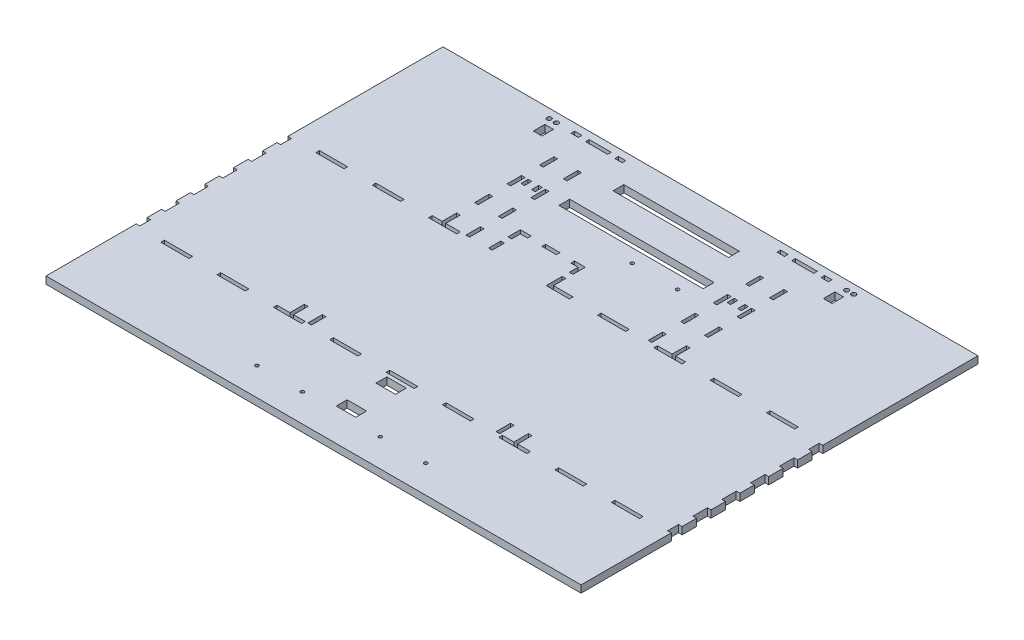
from build123d import *

# Parameters (mm, degrees)
SKETCH1_W                   = 470.789
SKETCH1_H                   = 139.7
BOSS_EXTRUDE1_DEPTH         = 6.35
SKETCH2_W                   = 470.789
SKETCH2_H                   = 139.7
SKETCH2_W_2                 = 464.439
SKETCH2_H_2                 = 133.35
BOSS_EXTRUDE2_DEPTH         = 298.45
SKETCH3_W                   = 5.588
SKETCH3_H                   = 16.933333333
SKETCH3_H_2                 = 16.933333334
DOOR_SLOT_DEPTH             = 12.7
SKETCH4_W                   = 6.35
SKETCH4_H                   = 15.875
DOOR_GUIDE_HOLES_DEPTH      = 3.175
LEVERHOLE_CUT_REACH         = 141.7
LEVER_HOLES_R               = 1.5
LEVER_HOLES_W               = 25.4
LEVER_HOLES_H               = 7.62
LEVER_HOLES_W_2             = 4
LEVER_HOLES_H_2             = 6.35
LEVER_HOLES_2_R             = 1.5
LBRACKET_THRU_HOLES_DEPTH   = 140.7
SKETCH8_R                   = 3.175
TETHER_HOLE_DEPTH           = 471.789
DOOR_GUIDE_ROOF_SLOTS_REACH = 141.7
SKETCH16_W                  = 9.525
SKETCH16_H                  = 9.271
SKETCH17_W                  = 470.789
SKETCH17_H                  = 298.45
CUT_EXTRUDE10_DEPTH         = 140.7
BOTTOM_W                    = 24.778368421
BOTTOM_H                    = 3.175
BOTTOM_W_2                  = 24.778368422
BOTTOM_W_3                  = 3.175
BOTTOM_H_2                  = 9.525
BOTTOM_H_3                  = 12.7
CUT_EXTRUDE11_DEPTH         = 7.35
SKETCH18_W                  = 470.789
SKETCH18_H                  = 76.2
SKETCH18_W_2                = 6.477
SKETCH18_H_2                = 3.175
SKETCH18_W_3                = 19.431
SKETCH18_W_4                = 3.175
SKETCH18_H_3                = 12.7
SKETCH18_W_5                = 12.7
BOSS_EXTRUDE3_DEPTH         = 6.35
SKETCH19_R                  = 1.499997
SKETCH19_R_2                = 2
SKETCH19_W                  = 3.175
SKETCH19_H                  = 6.35
CUT_EXTRUDE12_DEPTH         = 7.35
SKETCH20_W                  = 3.175
SKETCH20_H                  = 12.7
CUT_EXTRUDE13_DEPTH         = 7.35
SKETCH21_W                  = 17.145
SKETCH21_H                  = 9.525
SKETCH21_W_2                = 7.62
SKETCH21_H_2                = 10.16
SKETCH21_W_3                = 101.6
SKETCH21_W_4                = 127
WIRE_HOLES_DEPTH            = 7.35


with BuildPart() as part:
    # Sketch1 → Boss-Extrude1 (new body)
    with BuildSketch(Plane(origin=(0, 0, 0), x_dir=(1, 0, 0), z_dir=(0, 1, 0))):
        Rectangle(SKETCH1_W, SKETCH1_H)
    extrude(amount=BOSS_EXTRUDE1_DEPTH)

    # Sketch2 → Boss-Extrude2 (add)
    with BuildSketch(Plane(origin=(0, 6.35, 0), x_dir=(1, 0, 0), z_dir=(0, 1, 0))):
        Rectangle(SKETCH2_W, SKETCH2_H)
        Rectangle(SKETCH2_W_2, SKETCH2_H_2, mode=Mode.SUBTRACT)
    extrude(amount=BOSS_EXTRUDE2_DEPTH)

    # Sketch3 → Door Slot (cut)
    with BuildSketch(Plane.XY.offset(69.85)):
        with BuildLine():
            Line((70.1675, 292.354), (70.1675, 6.35))
            Line((70.1675, 6.35), (76.7715, 6.35))
            Line((76.7715, 6.35), (76.7715, 283.240675824))
            ThreePointArc((76.7715, 283.240675824), (77.515448776, 285.036727048), (79.3115, 285.780675824))
            Line((79.3115, 285.780675824), (89.7255, 285.780675824))
            Line((89.7255, 285.780675824), (89.7255, 292.354))
            Line((89.7255, 292.354), (70.1675, 292.354))
        make_face()
        with Locations((60.2615, 80.433333334)):
            Rectangle(SKETCH3_W, SKETCH3_H)
        with Locations((60.2615, 50.8)):
            Rectangle(SKETCH3_W, SKETCH3_H_2)
        with Locations((60.2615, 21.166666667)):
            Rectangle(SKETCH3_W, SKETCH3_H)
        with BuildLine():
            Line((-76.7715, 283.240675824), (-76.7715, 6.35))
            Line((-76.7715, 6.35), (-70.1675, 6.35))
            Line((-70.1675, 6.35), (-70.1675, 292.354))
            Line((-70.1675, 292.354), (-89.7255, 292.354))
            Line((-89.7255, 292.354), (-89.7255, 285.780675824))
            Line((-89.7255, 285.780675824), (-79.3115, 285.780675824))
            ThreePointArc((-79.3115, 285.780675824), (-77.515448776, 285.036727048), (-76.7715, 283.240675824))
        make_face()
        with Locations((-60.2615, 80.433333334)):
            Rectangle(SKETCH3_W, SKETCH3_H)
        with Locations((-60.2615, 50.8)):
            Rectangle(SKETCH3_W, SKETCH3_H_2)
        with Locations((-60.2615, 21.166666667)):
            Rectangle(SKETCH3_W, SKETCH3_H)
    extrude(amount=-DOOR_SLOT_DEPTH, mode=Mode.SUBTRACT)

    # Sketch4 → Door Guide Holes (cut)
    with BuildSketch(Plane.XY.offset(-66.675)):
        with Locations((66.9925, 255.5875)):
            Rectangle(SKETCH4_W, SKETCH4_H)
        with Locations((66.9925, 227.0125)):
            Rectangle(SKETCH4_W, SKETCH4_H)
        with Locations((66.9925, 198.4375)):
            Rectangle(SKETCH4_W, SKETCH4_H)
        with Locations((66.9925, 169.8625)):
            Rectangle(SKETCH4_W, SKETCH4_H)
        with Locations((66.9925, 141.2875)):
            Rectangle(SKETCH4_W, SKETCH4_H)
        with Locations((66.9925, 112.7125)):
            Rectangle(SKETCH4_W, SKETCH4_H)
        with Locations((66.9925, 84.1375)):
            Rectangle(SKETCH4_W, SKETCH4_H)
        with Locations((66.9925, 55.5625)):
            Rectangle(SKETCH4_W, SKETCH4_H)
        with Locations((66.9925, 26.9875)):
            Rectangle(SKETCH4_W, SKETCH4_H)
        with Locations((-92.9005, 284.1625)):
            Rectangle(SKETCH4_W, SKETCH4_H)
        with Locations((-92.9005, 255.5875)):
            Rectangle(SKETCH4_W, SKETCH4_H)
        with Locations((-92.9005, 227.0125)):
            Rectangle(SKETCH4_W, SKETCH4_H)
        with Locations((-92.9005, 198.4375)):
            Rectangle(SKETCH4_W, SKETCH4_H)
        with Locations((-92.9005, 169.8625)):
            Rectangle(SKETCH4_W, SKETCH4_H)
        with Locations((-92.9005, 141.2875)):
            Rectangle(SKETCH4_W, SKETCH4_H)
        with Locations((-92.9005, 112.7125)):
            Rectangle(SKETCH4_W, SKETCH4_H)
        with Locations((-92.9005, 84.1375)):
            Rectangle(SKETCH4_W, SKETCH4_H)
        with Locations((-92.9005, 55.5625)):
            Rectangle(SKETCH4_W, SKETCH4_H)
        with Locations((-92.9005, 26.9875)):
            Rectangle(SKETCH4_W, SKETCH4_H)
        with Locations((92.9005, 284.1625)):
            Rectangle(SKETCH4_W, SKETCH4_H)
        with Locations((92.9005, 255.5875)):
            Rectangle(SKETCH4_W, SKETCH4_H)
        with Locations((92.9005, 227.0125)):
            Rectangle(SKETCH4_W, SKETCH4_H)
        with Locations((92.9005, 198.4375)):
            Rectangle(SKETCH4_W, SKETCH4_H)
        with Locations((92.9005, 169.8625)):
            Rectangle(SKETCH4_W, SKETCH4_H)
        with Locations((92.9005, 141.2875)):
            Rectangle(SKETCH4_W, SKETCH4_H)
        with Locations((92.9005, 112.7125)):
            Rectangle(SKETCH4_W, SKETCH4_H)
        with Locations((92.9005, 84.1375)):
            Rectangle(SKETCH4_W, SKETCH4_H)
        with Locations((92.9005, 55.5625)):
            Rectangle(SKETCH4_W, SKETCH4_H)
        with Locations((92.9005, 26.9875)):
            Rectangle(SKETCH4_W, SKETCH4_H)
        with Locations((-66.9925, 284.1625)):
            Rectangle(SKETCH4_W, SKETCH4_H)
        with Locations((-66.9925, 255.5875)):
            Rectangle(SKETCH4_W, SKETCH4_H)
        with Locations((-66.9925, 227.0125)):
            Rectangle(SKETCH4_W, SKETCH4_H)
        with Locations((-66.9925, 198.4375)):
            Rectangle(SKETCH4_W, SKETCH4_H)
        with Locations((-66.9925, 169.8625)):
            Rectangle(SKETCH4_W, SKETCH4_H)
        with Locations((-66.9925, 141.2875)):
            Rectangle(SKETCH4_W, SKETCH4_H)
        with Locations((-66.9925, 112.7125)):
            Rectangle(SKETCH4_W, SKETCH4_H)
        with Locations((-66.9925, 84.1375)):
            Rectangle(SKETCH4_W, SKETCH4_H)
        with Locations((-66.9925, 55.5625)):
            Rectangle(SKETCH4_W, SKETCH4_H)
        with Locations((-66.9925, 26.9875)):
            Rectangle(SKETCH4_W, SKETCH4_H)
        with Locations((66.9925, 284.1625)):
            Rectangle(SKETCH4_W, SKETCH4_H)
    extrude(amount=-DOOR_GUIDE_HOLES_DEPTH, mode=Mode.SUBTRACT)

    # Lever Holes → LeverHole Cut (cut, up to next)
    with BuildSketch(Plane.XY.offset(-69.85), mode=Mode.PRIVATE) as leverhole_cut_sk1:
        with Locations((216.3445, 160.275)):
            Circle(LEVER_HOLES_R)
    leverhole_cut_tool1 = extrude(leverhole_cut_sk1.sketch, amount=LEVERHOLE_CUT_REACH, mode=Mode.PRIVATE) & part.part
    add(leverhole_cut_tool1.solids().sort_by_distance((216.3445, 160.275, -69.85))[0], mode=Mode.SUBTRACT)
    # Lever Holes → LeverHole Cut (cut, up to next)
    with BuildSketch(Plane.XY.offset(-69.85), mode=Mode.PRIVATE) as leverhole_cut_sk2:
        with Locations((216.3445, 144.525)):
            Circle(LEVER_HOLES_R)
    leverhole_cut_tool2 = extrude(leverhole_cut_sk2.sketch, amount=LEVERHOLE_CUT_REACH, mode=Mode.PRIVATE) & part.part
    add(leverhole_cut_tool2.solids().sort_by_distance((216.3445, 144.525, -69.85))[0], mode=Mode.SUBTRACT)
    # Lever Holes → LeverHole Cut (cut, up to next)
    with BuildSketch(Plane.XY.offset(-69.85), mode=Mode.PRIVATE) as leverhole_cut_sk3:
        with Locations((-216.3445, 160.275)):
            Circle(LEVER_HOLES_R)
    leverhole_cut_tool3 = extrude(leverhole_cut_sk3.sketch, amount=LEVERHOLE_CUT_REACH, mode=Mode.PRIVATE) & part.part
    add(leverhole_cut_tool3.solids().sort_by_distance((-216.3445, 160.275, -69.85))[0], mode=Mode.SUBTRACT)
    # Lever Holes → LeverHole Cut (cut, up to next)
    with BuildSketch(Plane.XY.offset(-69.85), mode=Mode.PRIVATE) as leverhole_cut_sk4:
        with Locations((-216.3445, 144.525)):
            Circle(LEVER_HOLES_R)
    leverhole_cut_tool4 = extrude(leverhole_cut_sk4.sketch, amount=LEVERHOLE_CUT_REACH, mode=Mode.PRIVATE) & part.part
    add(leverhole_cut_tool4.solids().sort_by_distance((-216.3445, 144.525, -69.85))[0], mode=Mode.SUBTRACT)
    # Lever Holes → LeverHole Cut (cut, up to next)
    with BuildSketch(Plane.XY.offset(-69.85), mode=Mode.PRIVATE) as leverhole_cut_sk5:
        with Locations((-40.5675, 33.8749894)):
            Rectangle(LEVER_HOLES_W, LEVER_HOLES_H)
    leverhole_cut_tool5 = extrude(leverhole_cut_sk5.sketch, amount=LEVERHOLE_CUT_REACH, mode=Mode.PRIVATE) & part.part
    add(leverhole_cut_tool5.solids().sort_by_distance((-40.5675, 33.874989, -69.85))[0], mode=Mode.SUBTRACT)
    # Lever Holes → LeverHole Cut (cut, up to next)
    with BuildSketch(Plane.XY.offset(-69.85), mode=Mode.PRIVATE) as leverhole_cut_sk6:
        with Locations((-51.8175, 13.175)):
            Rectangle(LEVER_HOLES_W_2, LEVER_HOLES_H_2)
    leverhole_cut_tool6 = extrude(leverhole_cut_sk6.sketch, amount=LEVERHOLE_CUT_REACH, mode=Mode.PRIVATE) & part.part
    add(leverhole_cut_tool6.solids().sort_by_distance((-51.8175, 13.175, -69.85))[0], mode=Mode.SUBTRACT)
    # Lever Holes → LeverHole Cut (cut, up to next)
    with BuildSketch(Plane.XY.offset(-69.85), mode=Mode.PRIVATE) as leverhole_cut_sk7:
        with Locations((-5.8175068, 13.175)):
            Rectangle(LEVER_HOLES_W_2, LEVER_HOLES_H_2)
    leverhole_cut_tool7 = extrude(leverhole_cut_sk7.sketch, amount=LEVERHOLE_CUT_REACH, mode=Mode.PRIVATE) & part.part
    add(leverhole_cut_tool7.solids().sort_by_distance((-5.817507, 13.175, -69.85))[0], mode=Mode.SUBTRACT)
    # Lever Holes → LeverHole Cut (cut, up to next)
    with BuildSketch(Plane.XY.offset(-69.85), mode=Mode.PRIVATE) as leverhole_cut_sk8:
        with Locations((5.8175068, 13.175)):
            Rectangle(LEVER_HOLES_W_2, LEVER_HOLES_H_2)
    leverhole_cut_tool8 = extrude(leverhole_cut_sk8.sketch, amount=LEVERHOLE_CUT_REACH, mode=Mode.PRIVATE) & part.part
    add(leverhole_cut_tool8.solids().sort_by_distance((5.817507, 13.175, -69.85))[0], mode=Mode.SUBTRACT)
    # Lever Holes → LeverHole Cut (cut, up to next)
    with BuildSketch(Plane.XY.offset(-69.85), mode=Mode.PRIVATE) as leverhole_cut_sk9:
        with Locations((40.5675, 33.8749894)):
            Rectangle(LEVER_HOLES_W, LEVER_HOLES_H)
    leverhole_cut_tool9 = extrude(leverhole_cut_sk9.sketch, amount=LEVERHOLE_CUT_REACH, mode=Mode.PRIVATE) & part.part
    add(leverhole_cut_tool9.solids().sort_by_distance((40.5675, 33.874989, -69.85))[0], mode=Mode.SUBTRACT)
    # Lever Holes → LeverHole Cut (cut, up to next)
    with BuildSketch(Plane.XY.offset(-69.85), mode=Mode.PRIVATE) as leverhole_cut_sk10:
        with Locations((51.8175, 13.175)):
            Rectangle(LEVER_HOLES_W_2, LEVER_HOLES_H_2)
    leverhole_cut_tool10 = extrude(leverhole_cut_sk10.sketch, amount=LEVERHOLE_CUT_REACH, mode=Mode.PRIVATE) & part.part
    add(leverhole_cut_tool10.solids().sort_by_distance((51.8175, 13.175, -69.85))[0], mode=Mode.SUBTRACT)

    # Lever Holes_2 → Lbracket Thru Holes (cut, through all)
    with BuildSketch(Plane.XY.offset(-69.85)):
        with Locations((-216.3445, 160.275)):
            Circle(LEVER_HOLES_2_R)
        with Locations((-216.3445, 144.525)):
            Circle(LEVER_HOLES_2_R)
        with Locations((216.3445, 160.275)):
            Circle(LEVER_HOLES_2_R)
        with Locations((216.3445, 144.525)):
            Circle(LEVER_HOLES_2_R)
    extrude(amount=LBRACKET_THRU_HOLES_DEPTH, mode=Mode.SUBTRACT)

    # Sketch8 → Tether Hole (cut, through all)
    with BuildSketch(Plane.ZY.offset(235.3945)):
        with Locations((0, 19.05)):
            Circle(SKETCH8_R)
    extrude(amount=-TETHER_HOLE_DEPTH, mode=Mode.SUBTRACT)

    # Sketch16 → Door Guide Roof Slots (cut, up to next)
    with BuildSketch(Plane.XY.offset(69.85), mode=Mode.PRIVATE) as door_guide_roof_slots_sk1:
        with Locations((52.578, 300.1645)):
            Rectangle(SKETCH16_W, SKETCH16_H)
    door_guide_roof_slots_tool1 = extrude(door_guide_roof_slots_sk1.sketch, amount=-DOOR_GUIDE_ROOF_SLOTS_REACH, mode=Mode.PRIVATE) & part.part
    add(door_guide_roof_slots_tool1.solids().sort_by_distance((52.578, 300.1645, 69.85))[0], mode=Mode.SUBTRACT)
    # Sketch16 → Door Guide Roof Slots (cut, up to next)
    with BuildSketch(Plane.XY.offset(69.85), mode=Mode.PRIVATE) as door_guide_roof_slots_sk2:
        with Locations((107.315, 300.1645)):
            Rectangle(SKETCH16_W, SKETCH16_H)
    door_guide_roof_slots_tool2 = extrude(door_guide_roof_slots_sk2.sketch, amount=-DOOR_GUIDE_ROOF_SLOTS_REACH, mode=Mode.PRIVATE) & part.part
    add(door_guide_roof_slots_tool2.solids().sort_by_distance((107.315, 300.1645, 69.85))[0], mode=Mode.SUBTRACT)
    # Sketch16 → Door Guide Roof Slots (cut, up to next)
    with BuildSketch(Plane.XY.offset(69.85), mode=Mode.PRIVATE) as door_guide_roof_slots_sk3:
        with Locations((-107.315, 300.1645)):
            Rectangle(SKETCH16_W, SKETCH16_H)
    door_guide_roof_slots_tool3 = extrude(door_guide_roof_slots_sk3.sketch, amount=-DOOR_GUIDE_ROOF_SLOTS_REACH, mode=Mode.PRIVATE) & part.part
    add(door_guide_roof_slots_tool3.solids().sort_by_distance((-107.315, 300.1645, 69.85))[0], mode=Mode.SUBTRACT)
    # Sketch16 → Door Guide Roof Slots (cut, up to next)
    with BuildSketch(Plane.XY.offset(69.85), mode=Mode.PRIVATE) as door_guide_roof_slots_sk4:
        with Locations((-52.578, 300.1645)):
            Rectangle(SKETCH16_W, SKETCH16_H)
    door_guide_roof_slots_tool4 = extrude(door_guide_roof_slots_sk4.sketch, amount=-DOOR_GUIDE_ROOF_SLOTS_REACH, mode=Mode.PRIVATE) & part.part
    add(door_guide_roof_slots_tool4.solids().sort_by_distance((-52.578, 300.1645, 69.85))[0], mode=Mode.SUBTRACT)

    # Sketch17 → Cut-Extrude10 (cut, through all)
    with BuildSketch(Plane.XY.offset(69.85)):
        with Locations((0, 155.575)):
            Rectangle(SKETCH17_W, SKETCH17_H)
    extrude(amount=-CUT_EXTRUDE10_DEPTH, mode=Mode.SUBTRACT)

    # Bottom → Cut-Extrude11 (cut, through all)
    with BuildSketch(Plane.XZ):
        with Locations((-198.226947369, 68.2625)):
            Rectangle(BOTTOM_W, BOTTOM_H)
        with Locations((-148.670210527, 68.2625)):
            Rectangle(BOTTOM_W, BOTTOM_H)
        with Locations((-99.113473685, 68.2625)):
            Rectangle(BOTTOM_W, BOTTOM_H)
        with Locations((-49.556736843, 68.2625)):
            Rectangle(BOTTOM_W, BOTTOM_H)
        with Locations((0, 68.2625)):
            Rectangle(BOTTOM_W_2, BOTTOM_H)
        with Locations((49.556736843, 68.2625)):
            Rectangle(BOTTOM_W, BOTTOM_H)
        with Locations((99.113473685, 68.2625)):
            Rectangle(BOTTOM_W, BOTTOM_H)
        with Locations((148.670210527, 68.2625)):
            Rectangle(BOTTOM_W, BOTTOM_H)
        with Locations((198.226947369, 68.2625)):
            Rectangle(BOTTOM_W, BOTTOM_H)
        with Locations((233.807, 61.9125)):
            Rectangle(BOTTOM_W_3, BOTTOM_H_2)
        with Locations((233.807, 38.1)):
            Rectangle(BOTTOM_W_3, BOTTOM_H_3)
        with Locations((233.807, 12.7)):
            Rectangle(BOTTOM_W_3, BOTTOM_H_3)
        with Locations((233.807, -12.7)):
            Rectangle(BOTTOM_W_3, BOTTOM_H_3)
        with Locations((233.807, -38.1)):
            Rectangle(BOTTOM_W_3, BOTTOM_H_3)
        with Locations((233.807, -61.9125)):
            Rectangle(BOTTOM_W_3, BOTTOM_H_2)
        with Locations((198.226947369, -68.2625)):
            Rectangle(BOTTOM_W, BOTTOM_H)
        with Locations((148.670210527, -68.2625)):
            Rectangle(BOTTOM_W, BOTTOM_H)
        with Locations((99.113473685, -68.2625)):
            Rectangle(BOTTOM_W, BOTTOM_H)
        with Locations((49.556736843, -68.2625)):
            Rectangle(BOTTOM_W, BOTTOM_H)
        with Locations((0, -68.2625)):
            Rectangle(BOTTOM_W_2, BOTTOM_H)
        with Locations((-99.113473685, -68.2625)):
            Rectangle(BOTTOM_W, BOTTOM_H)
        with Locations((-148.670210527, -68.2625)):
            Rectangle(BOTTOM_W, BOTTOM_H)
        with Locations((-198.226947369, -68.2625)):
            Rectangle(BOTTOM_W, BOTTOM_H)
        with Locations((-233.807, -61.9125)):
            Rectangle(BOTTOM_W_3, BOTTOM_H_2)
        with Locations((-233.807, -38.1)):
            Rectangle(BOTTOM_W_3, BOTTOM_H_3)
        with Locations((-233.807, -12.7)):
            Rectangle(BOTTOM_W_3, BOTTOM_H_3)
        with Locations((-233.807, 12.7)):
            Rectangle(BOTTOM_W_3, BOTTOM_H_3)
        with Locations((-233.807, 38.1)):
            Rectangle(BOTTOM_W_3, BOTTOM_H_3)
        with Locations((-233.807, 61.9125)):
            Rectangle(BOTTOM_W_3, BOTTOM_H_2)
    extrude(amount=-CUT_EXTRUDE11_DEPTH, mode=Mode.SUBTRACT)

    # Sketch18 → Boss-Extrude3 (add)
    with BuildSketch(Plane.XZ):
        with Locations((0, 107.95)):
            Rectangle(SKETCH18_W, SKETCH18_H)
        Polygon((-102.743, -69.85), (-235.3945, -69.85), (-235.3945, -203.2), (235.3945, -203.2), (235.3945, -69.85), (102.743, -69.85), (102.743, -82.55), (99.568, -82.55), (99.568, -69.85), (81.788, -69.85), (81.788, -82.55), (78.613, -82.55), (78.613, -69.85), (-4.795929074, -69.85), (-4.795929074, -80.6749974), (-7.970929074, -80.6749974), (-7.970929074, -66.675), (-12.389184211, -66.675), (-12.389184211, -69.85), (-58.770929074, -69.85), (-58.770929074, -80.6749974), (-61.945929074, -80.6749974), (-61.945929074, -69.85), (-78.613, -69.85), (-78.613, -82.55), (-81.788, -82.55), (-81.788, -69.85), (-99.568, -69.85), (-99.568, -82.55), (-102.743, -82.55), align=None)
        with Locations((-109.982, -195.2625)):
            Rectangle(SKETCH18_W_2, SKETCH18_H_2, mode=Mode.SUBTRACT)
        with Locations((-90.678, -195.2625)):
            Rectangle(SKETCH18_W_3, SKETCH18_H_2, mode=Mode.SUBTRACT)
        with Locations((-71.374, -195.2625)):
            Rectangle(SKETCH18_W_2, SKETCH18_H_2, mode=Mode.SUBTRACT)
        with Locations((71.374, -195.2625)):
            Rectangle(SKETCH18_W_2, SKETCH18_H_2, mode=Mode.SUBTRACT)
        with Locations((90.678, -195.2625)):
            Rectangle(SKETCH18_W_3, SKETCH18_H_2, mode=Mode.SUBTRACT)
        with Locations((109.982, -195.2625)):
            Rectangle(SKETCH18_W_2, SKETCH18_H_2, mode=Mode.SUBTRACT)
        with Locations((-101.1555, -161.925)):
            Rectangle(SKETCH18_W_4, SKETCH18_H_3, mode=Mode.SUBTRACT)
        with Locations((-80.2005, -161.925)):
            Rectangle(SKETCH18_W_4, SKETCH18_H_3, mode=Mode.SUBTRACT)
        with Locations((-101.1555, -133.35)):
            Rectangle(SKETCH18_W_4, SKETCH18_H_3, mode=Mode.SUBTRACT)
        with Locations((-80.2005, -133.35)):
            Rectangle(SKETCH18_W_4, SKETCH18_H_3, mode=Mode.SUBTRACT)
        with Locations((-101.1555, -104.775)):
            Rectangle(SKETCH18_W_4, SKETCH18_H_3, mode=Mode.SUBTRACT)
        with Locations((-80.2005, -104.775)):
            Rectangle(SKETCH18_W_4, SKETCH18_H_3, mode=Mode.SUBTRACT)
        with Locations((-33.370929074, -96.2624948)):
            Rectangle(SKETCH18_W_5, SKETCH18_H_2, mode=Mode.SUBTRACT)
        Polygon((-61.945929074, -97.8499948), (-61.945929074, -87.0249974), (-58.770929074, -87.0249974), (-58.770929074, -94.6749948), (-52.420929074, -94.6749948), (-52.420929074, -97.8499948), align=None, mode=Mode.SUBTRACT)
        Polygon((-14.320929074, -97.8499948), (-14.320929074, -94.6749948), (-7.970929074, -94.6749948), (-7.970929074, -87.0249974), (-4.795929074, -87.0249974), (-4.795929074, -97.8499948), align=None, mode=Mode.SUBTRACT)
        with Locations((80.2005, -161.925)):
            Rectangle(SKETCH18_W_4, SKETCH18_H_3, mode=Mode.SUBTRACT)
        with Locations((101.1555, -161.925)):
            Rectangle(SKETCH18_W_4, SKETCH18_H_3, mode=Mode.SUBTRACT)
        with Locations((80.2005, -133.35)):
            Rectangle(SKETCH18_W_4, SKETCH18_H_3, mode=Mode.SUBTRACT)
        with Locations((101.1555, -133.35)):
            Rectangle(SKETCH18_W_4, SKETCH18_H_3, mode=Mode.SUBTRACT)
        with Locations((80.2005, -104.775)):
            Rectangle(SKETCH18_W_4, SKETCH18_H_3, mode=Mode.SUBTRACT)
        with Locations((101.1555, -104.775)):
            Rectangle(SKETCH18_W_4, SKETCH18_H_3, mode=Mode.SUBTRACT)
    extrude(amount=-BOSS_EXTRUDE3_DEPTH)

    # Sketch19 → Cut-Extrude12 (cut, through all)
    with BuildSketch(Plane.XZ):
        with Locations((74.275300066, 121.55)):
            Circle(SKETCH19_R)
        with Locations((34.275309866, 121.55)):
            Circle(SKETCH19_R)
        with Locations((-34.275309866, 121.55)):
            Circle(SKETCH19_R)
        with Locations((-74.275300066, 121.55)):
            Circle(SKETCH19_R)
        with Locations((12.817510052, -121.55)):
            Circle(SKETCH19_R)
        with Locations((52.817500252, -121.55)):
            Circle(SKETCH19_R)
        with Locations((127.635, -195.2625)):
            Circle(SKETCH19_R_2)
        with Locations((133.985, -195.2625)):
            Circle(SKETCH19_R_2)
        with Locations((-127.635, -195.2625)):
            Circle(SKETCH19_R_2)
        with Locations((-133.985, -195.2625)):
            Circle(SKETCH19_R_2)
        with Locations((-86.0044, -136.525)):
            Rectangle(SKETCH19_W, SKETCH19_H)
        with Locations((-95.3516, -136.525)):
            Rectangle(SKETCH19_W, SKETCH19_H)
        with Locations((86.0044, -136.525)):
            Rectangle(SKETCH19_W, SKETCH19_H)
        with Locations((95.3516, -136.525)):
            Rectangle(SKETCH19_W, SKETCH19_H)
    extrude(amount=-CUT_EXTRUDE12_DEPTH, mode=Mode.SUBTRACT)

    # Sketch20 → Cut-Extrude13 (cut, through all)
    with BuildSketch(Plane(origin=(0, 0, 0), x_dir=(-1, 0, 0), z_dir=(0, -1, 0))):
        with Locations((-98.552, -60.325)):
            Rectangle(SKETCH20_W, SKETCH20_H)
        with Locations((-82.804, -60.325)):
            Rectangle(SKETCH20_W, SKETCH20_H)
        with Locations((82.804, -60.325)):
            Rectangle(SKETCH20_W, SKETCH20_H)
        with Locations((98.552, -60.325)):
            Rectangle(SKETCH20_W, SKETCH20_H)
    extrude(amount=-CUT_EXTRUDE13_DEPTH, mode=Mode.SUBTRACT)

    # Sketch21 → Wire Holes (cut, through all)
    with BuildSketch(Plane.XZ):
        with Locations((0, 77.7875)):
            Rectangle(SKETCH21_W, SKETCH21_H)
        with Locations((0, 112.7125)):
            Rectangle(SKETCH21_W, SKETCH21_H)
        with Locations((-127.635, -183.8325)):
            Rectangle(SKETCH21_W_2, SKETCH21_H_2)
        with Locations((127.635, -183.8325)):
            Rectangle(SKETCH21_W_2, SKETCH21_H_2)
        with Locations((0, -173.0375)):
            Rectangle(SKETCH21_W_3, SKETCH21_H)
        with Locations((0, -138.1125)):
            Rectangle(SKETCH21_W_4, SKETCH21_H)
    extrude(amount=-WIRE_HOLES_DEPTH, mode=Mode.SUBTRACT)


solid = part.part
